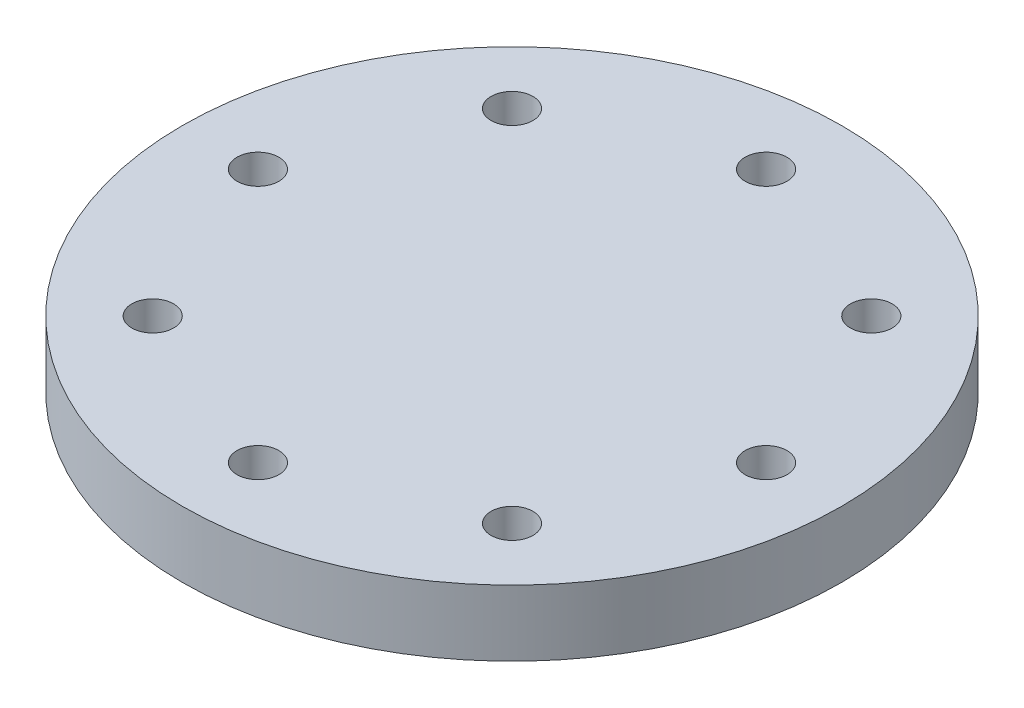
from build123d import *

# Parameters (mm, degrees)
SKETCH_1_R          = 50
SKETCH_1_R_2        = 3.175
EXTRUDE_1_DEPTH     = 10
SKETCH_1_8_R        = 11
EXTRUDE_2_DEPTH     = 25.5
SKETCH_4_R          = 3.175
CUT_EXTRUDE_1_DEPTH = 30
SKETCH_2_R          = 3.175
CUT_EXTRUDE_2_DEPTH = 30
EXTRUDE_3_DEPTH     = 10
EXTRUDE_4_DEPTH     = 10


with BuildPart() as part:
    # Sketch 1 → Extrude 1 (new body)
    with BuildSketch(Plane(origin=(0, 0, 0), x_dir=(1, 0, 0), z_dir=(0, 1, 0))):
        Circle(SKETCH_1_R)
        with BuildLine():
            Line((7, -2), (6.708203932, -2))
            ThreePointArc((6.708203932, -2), (-7, 0), (6.708203932, 2))
            Line((6.708203932, 2), (7, 2))
            Line((7, 2), (7, -2))
        make_face(mode=Mode.SUBTRACT)
        with Locations((0, -38.530339059)):
            Circle(SKETCH_1_R_2, mode=Mode.SUBTRACT)
        with Locations((0, 38.530339059)):
            Circle(SKETCH_1_R_2, mode=Mode.SUBTRACT)
        with Locations((-38.530339059, 0)):
            Circle(SKETCH_1_R_2, mode=Mode.SUBTRACT)
        with Locations((38.530339059, 0)):
            Circle(SKETCH_1_R_2, mode=Mode.SUBTRACT)
        with Locations((-27.24506403, -27.24506403)):
            Circle(SKETCH_1_R_2, mode=Mode.SUBTRACT)
        with Locations((27.24506403, -27.24506403)):
            Circle(SKETCH_1_R_2, mode=Mode.SUBTRACT)
        with Locations((27.24506403, 27.24506403)):
            Circle(SKETCH_1_R_2, mode=Mode.SUBTRACT)
        with Locations((-27.24506403, 27.24506403)):
            Circle(SKETCH_1_R_2, mode=Mode.SUBTRACT)
    extrude(amount=EXTRUDE_1_DEPTH)

    # Sketch 1_8 → Extrude 2 (add)
    with BuildSketch(Plane(origin=(0, 0, 0), x_dir=(1, 0, 0), z_dir=(0, 1, 0))):
        Circle(SKETCH_1_8_R)
        with BuildLine():
            Line((7, -2), (6.708203932, -2))
            ThreePointArc((6.708203932, -2), (-7, 0), (6.708203932, 2))
            Line((6.708203932, 2), (7, 2))
            Line((7, 2), (7, -2))
        make_face(mode=Mode.SUBTRACT)
    extrude(amount=-EXTRUDE_2_DEPTH)

    # Sketch 4 → Cut-Extrude 1 (cut)
    with BuildSketch(Plane(origin=(0, 0, 0), x_dir=(0, 0, -1), z_dir=(1, 0, 0))):
        with Locations((0, -8.219375354)):
            Circle(SKETCH_4_R)
        with Locations((0, -20.547213865)):
            Circle(SKETCH_4_R)
    extrude(amount=-CUT_EXTRUDE_1_DEPTH, mode=Mode.SUBTRACT)

    # Sketch 2 → Cut-Extrude 2 (cut)
    with BuildSketch(Plane.XY):
        with Locations((0, -6.856583625)):
            Circle(SKETCH_2_R)
        with Locations((0, -19.346548073)):
            Circle(SKETCH_2_R)
    extrude(amount=-CUT_EXTRUDE_2_DEPTH, mode=Mode.SUBTRACT)

    # Sketch 1_9 → Extrude 3 (add)
    with BuildSketch(Plane(origin=(0, 0, 0), x_dir=(1, 0, 0), z_dir=(0, 1, 0))):
        with BuildLine():
            Line((6.708203932, -2), (0, -2))
            Line((0, -2), (0, 2))
            Line((0, 2), (6.708203932, 2))
            ThreePointArc((6.708203932, 2), (-7, 0), (6.708203932, -2))
        make_face()
    extrude(amount=EXTRUDE_3_DEPTH)

    # Sketch 1_10 → Extrude 4 (add)
    with BuildSketch(Plane(origin=(0, 0, 0), x_dir=(1, 0, 0), z_dir=(0, 1, 0))):
        with BuildLine():
            Line((0, 2), (0, 0))
            Line((0, 0), (7, 0))
            ThreePointArc((7, 0), (6.926666858, 1.010587075), (6.708203932, 2))
            Line((6.708203932, 2), (0, 2))
        make_face()
        with BuildLine():
            Line((0, 0), (0, -2))
            Line((0, -2), (6.708203932, -2))
            ThreePointArc((6.708203932, -2), (6.926666858, -1.010587075), (7, 0))
            Line((7, 0), (0, 0))
        make_face()
        with BuildLine():
            ThreePointArc((7, 0), (6.926666858, -1.010587075), (6.708203932, -2))
            Line((6.708203932, -2), (7, -2))
            Line((7, -2), (7, 0))
        make_face()
        with BuildLine():
            ThreePointArc((6.708203932, 2), (6.926666858, 1.010587075), (7, 0))
            Line((7, 0), (7, 2))
            Line((7, 2), (6.708203932, 2))
        make_face()
    extrude(amount=EXTRUDE_4_DEPTH)


solid = part.part
